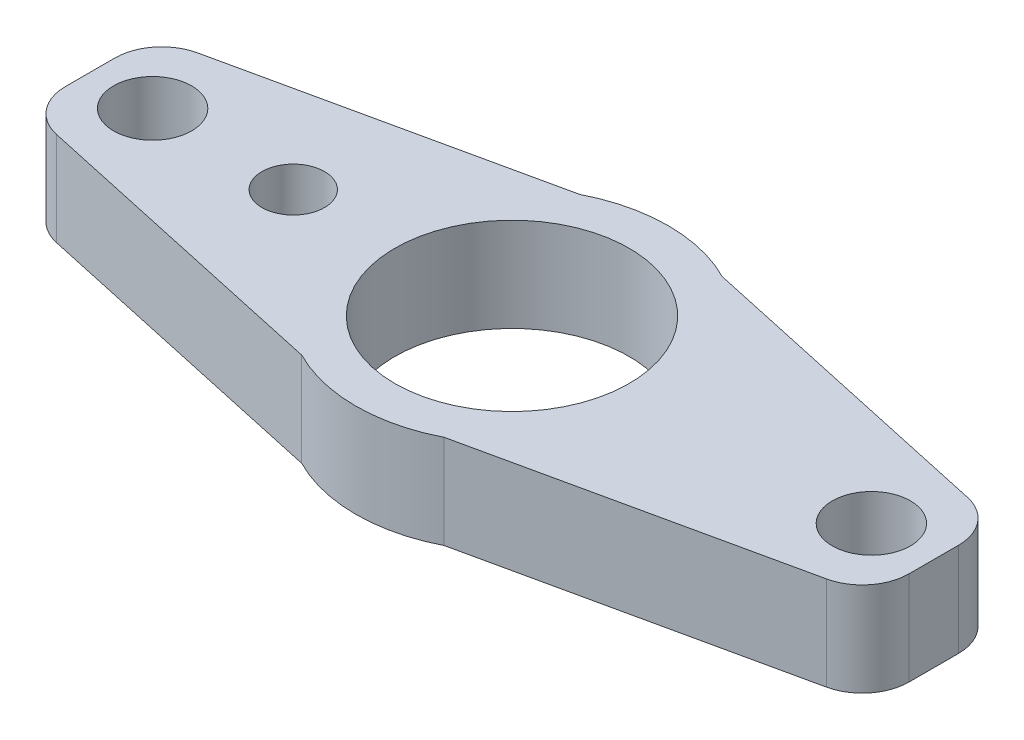
from build123d import *

# Parameters (mm, degrees)
SKETCH1_R           = 3.75
SKETCH1_R_2         = 1.25
SKETCH1_R_3         = 1
BOSS_EXTRUDE1_DEPTH = 3
FILLET1_R           = 1.5


with BuildPart() as part:
    # Sketch1 → Boss-Extrude1 (new body)
    with BuildSketch(Plane(origin=(0, 0, 0), x_dir=(1, 0, 0), z_dir=(0, 1, 0))):
        with BuildLine():
            Line((-2.277845841, 4.451001946), (-13.5, 2))
            Line((-13.5, 2), (-13.5, -2))
            Line((-13.5, -2), (-2.277845841, -4.451001946))
            ThreePointArc((-2.277845841, -4.451001946), (0, -5), (2.277845841, -4.451001946))
            Line((2.277845841, -4.451001946), (13.5, -2))
            Line((13.5, -2), (13.5, 2))
            Line((13.5, 2), (2.277845841, 4.451001946))
            ThreePointArc((2.277845841, 4.451001946), (0, 5), (-2.277845841, 4.451001946))
        make_face()
        Circle(SKETCH1_R, mode=Mode.SUBTRACT)
        with Locations((-11.5, 0)):
            Circle(SKETCH1_R_2, mode=Mode.SUBTRACT)
        with Locations((11.5, 0)):
            Circle(SKETCH1_R_2, mode=Mode.SUBTRACT)
        with Locations((-7, 0)):
            Circle(SKETCH1_R_3, mode=Mode.SUBTRACT)
    extrude(amount=BOSS_EXTRUDE1_DEPTH)

    # Fillet1
    fillet1_edges = [part.edges().sort_by_distance(p)[0] for p in [
        (-13.5, 1.5, 2),
        (-13.5, 1.5, -2),
        (13.5, 1.5, -2),
        (13.5, 1.5, 2),
    ]]
    fillet(fillet1_edges, radius=FILLET1_R)


solid = part.part
